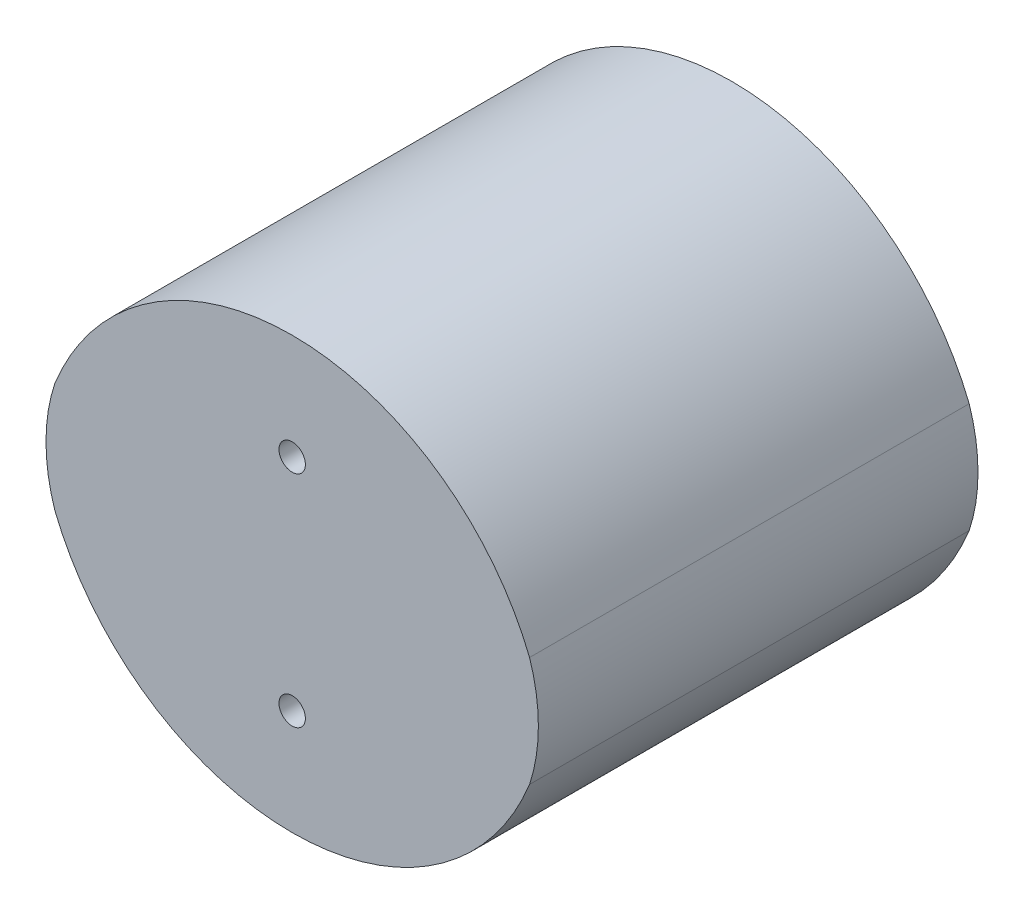
from build123d import *

# Parameters (mm, degrees)
BOSS_EXTRU_1_DEPTH            = 50
DIAM_TRE_DU_PER_AGE_3_0_3_1_D = 3


with BuildPart() as part:
    # Esquisse1 → Boss.-Extru.1 (new body)
    with BuildSketch(Plane.XY):
        with BuildLine():
            ThreePointArc((-26.998355192, 6.25), (-28, 0), (-26.998355192, -6.25))
            ThreePointArc((-26.998355192, -6.25), (0, -24.5), (26.998355192, -6.25))
            ThreePointArc((26.998355192, -6.25), (28, 0), (26.998355192, 6.25))
            ThreePointArc((26.998355192, 6.25), (0, 24.5), (-26.998355192, 6.25))
        make_face()
    extrude(amount=BOSS_EXTRU_1_DEPTH)

    # Diamètre du perçage Ø3.0 (3)1 (through all)
    with Locations(Plane.XY.offset(50)):
        with Locations((0, 12.5), (0, -12.5)):
            Hole(DIAM_TRE_DU_PER_AGE_3_0_3_1_D / 2)


solid = part.part
